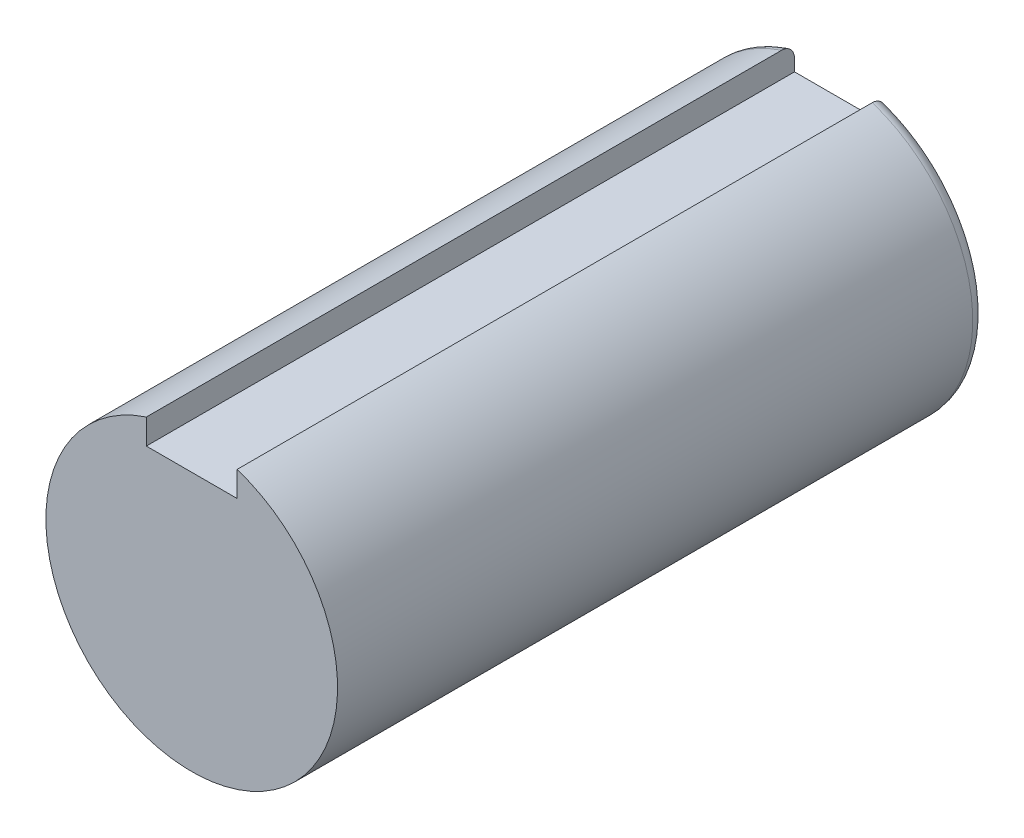
from build123d import *

# Parameters (mm, degrees)
SKETCH1_R           = 22.5
BOSS_EXTRUDE3_DEPTH = 100
SKETCH5_W           = 14
SKETCH5_H           = 7.800985848
CUT_EXTRUDE2_DEPTH  = 100
FILLET1_R           = 2


with BuildPart() as part:
    # Sketch1 → Boss-Extrude3 (new body)
    with BuildSketch(Plane.XY):
        Circle(SKETCH1_R)
    extrude(amount=BOSS_EXTRUDE3_DEPTH)

    # Sketch5 → Cut-Extrude2 (cut)
    with BuildSketch(Plane(origin=(0, 0, 0), x_dir=(-1, 0, 0), z_dir=(0, 0, -1))):
        with Locations((0, 21.400492924)):
            Rectangle(SKETCH5_W, SKETCH5_H)
    extrude(amount=-CUT_EXTRUDE2_DEPTH, mode=Mode.SUBTRACT)

    # Fillet1
    fillet1_edges = [part.edges().sort_by_distance(p)[0] for p in [
        (0, -22.5, 0),
    ]]
    fillet(fillet1_edges, radius=FILLET1_R)


solid = part.part
